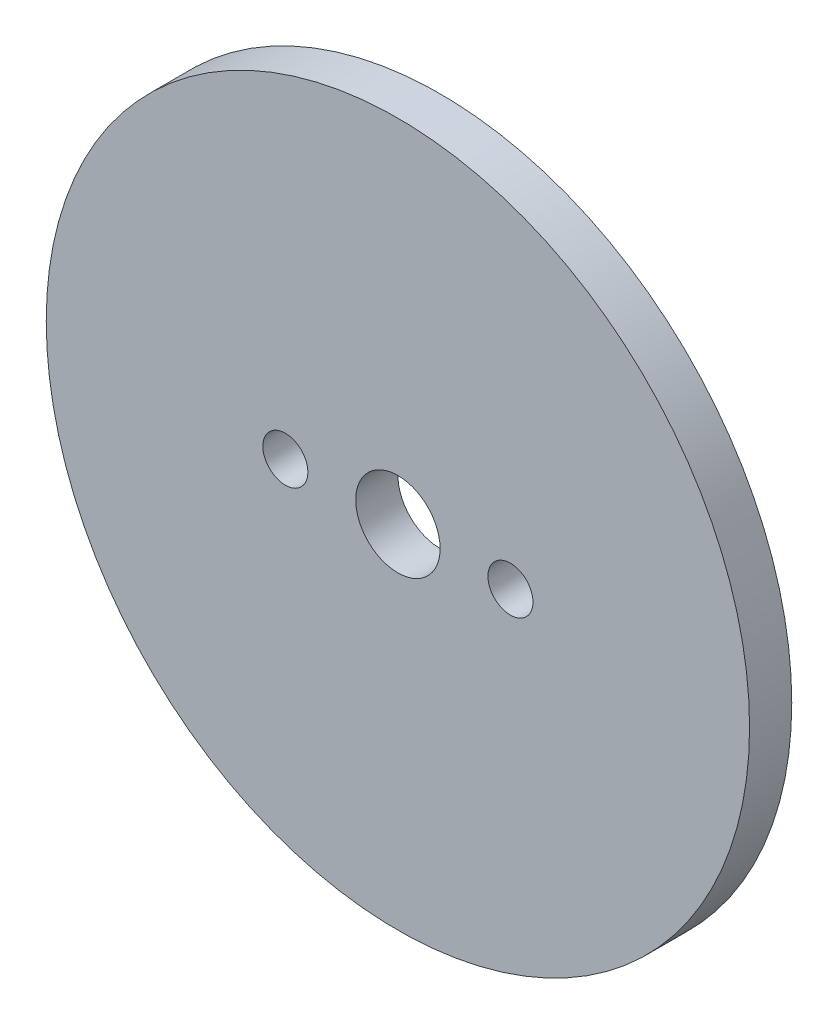
from build123d import *

# Parameters (mm, degrees)
ESBO_O1_R                = 25
ESBO_O1_R_2              = 3
ESBO_O1_R_3              = 1.6
RESSALTO_EXTRUS_O1_DEPTH = 1.5


with BuildPart() as part:
    # Esboço1 → Ressalto-extrusão1 (new body, symmetric)
    with BuildSketch(Plane.XY):
        Circle(ESBO_O1_R)
        Circle(ESBO_O1_R_2, mode=Mode.SUBTRACT)
        with Locations((-8, 0)):
            Circle(ESBO_O1_R_3, mode=Mode.SUBTRACT)
        with Locations((8, 0)):
            Circle(ESBO_O1_R_3, mode=Mode.SUBTRACT)
    extrude(amount=RESSALTO_EXTRUS_O1_DEPTH, both=True)


solid = part.part
